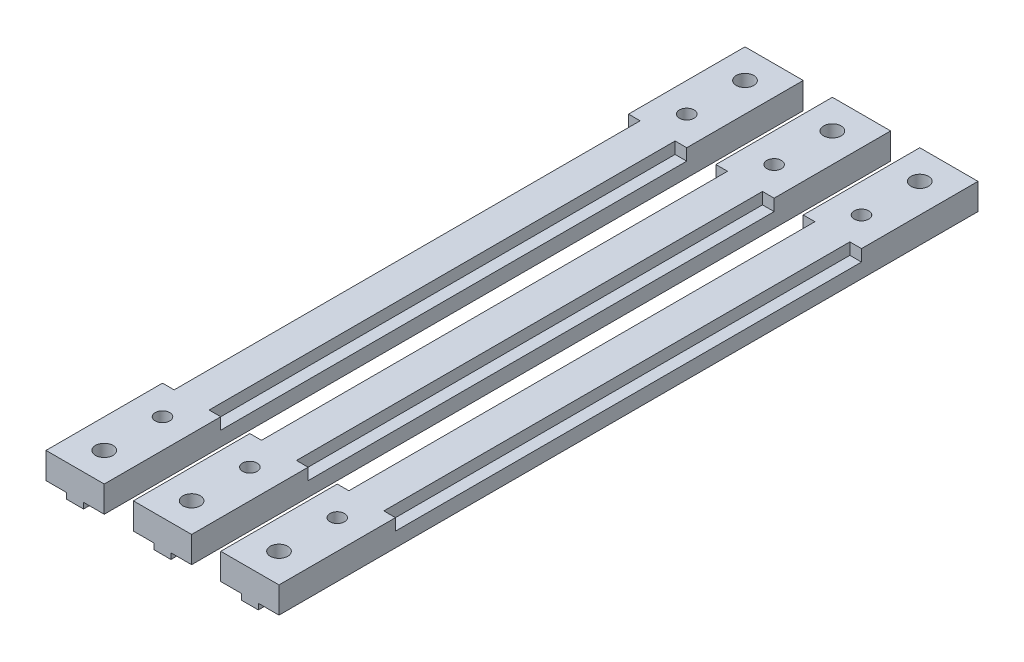
from build123d import *

# Parameters (mm, degrees)
MAIN_DEPTH      = 120
SKETCH2_R       = 1.25
SKETCH2_R_2     = 1.5
MAINHOLES_DEPTH = 6.5
SKETCH3_W       = 2
SKETCH3_H       = 80
PINHOLES_DEPTH  = 2
LPATTERN1_COUNT = 3
LPATTERN1_PITCH = 15


with BuildPart() as part:
    # Sketch1 → Main (new body)
    with BuildSketch(Plane.XY):
        Polygon((-5, 0), (5, 0), (5, -4.5), (1.45, -4.5), (1.45, -5.5), (-1.45, -5.5), (-1.45, -4.5), (-5, -4.5), align=None)
    extrude(amount=MAIN_DEPTH)

    # Sketch2 → MainHoles (cut, through all)
    with BuildSketch(Plane(origin=(0, 0, 0), x_dir=(1, 0, 0), z_dir=(0, 1, 0))):
        with Locations((0, -105)):
            Circle(SKETCH2_R)
        with Locations((0, -15)):
            Circle(SKETCH2_R)
        with Locations((0, -5)):
            Circle(SKETCH2_R_2)
        with Locations((0, -115)):
            Circle(SKETCH2_R_2)
    extrude(amount=-MAINHOLES_DEPTH, mode=Mode.SUBTRACT)

    # Sketch3 → PinHoles (cut)
    with BuildSketch(Plane(origin=(0, 0, 0), x_dir=(1, 0, 0), z_dir=(0, 1, 0))):
        with Locations((-4, -60)):
            Rectangle(SKETCH3_W, SKETCH3_H)
        with Locations((4, -60)):
            Rectangle(SKETCH3_W, SKETCH3_H)
    extrude(amount=-PINHOLES_DEPTH, mode=Mode.SUBTRACT)


with BuildPart() as lpattern1_1:
    # LPattern1: pattern copy
    add(part.part.moved(Location(Vector(1, 0, 0) * (1 * LPATTERN1_PITCH))))


with BuildPart() as lpattern1_2:
    # LPattern1: pattern copy
    add(part.part.moved(Location(Vector(1, 0, 0) * (2 * LPATTERN1_PITCH))))


solid = Compound([part.part, lpattern1_1.part, lpattern1_2.part])
